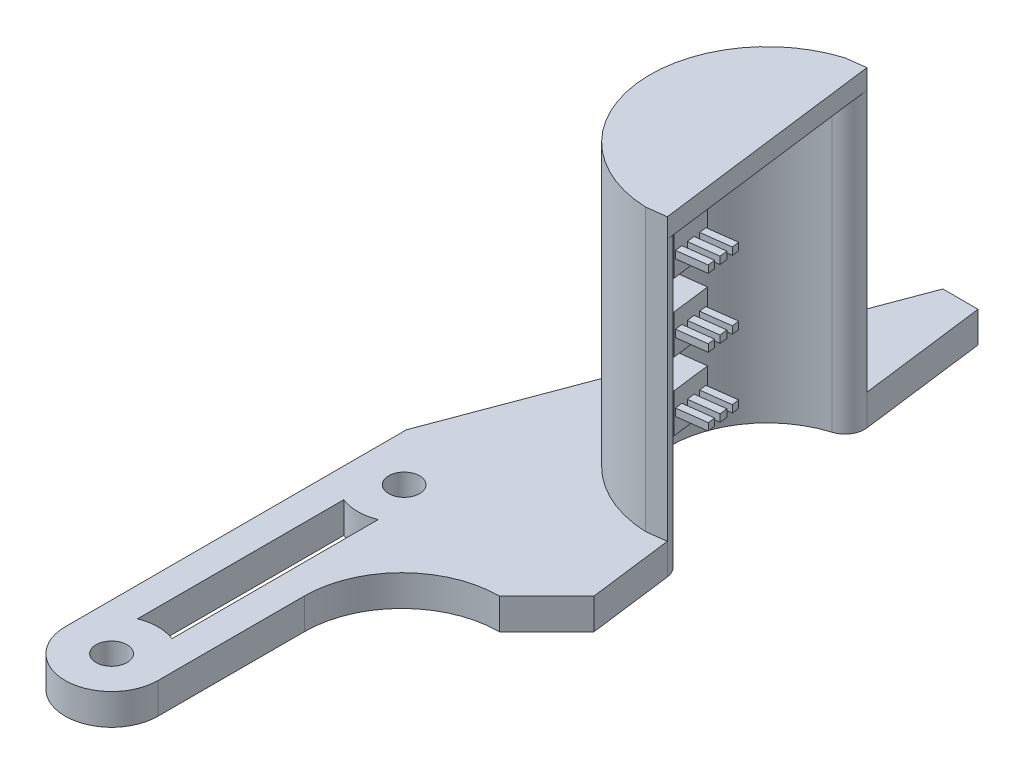
from build123d import *
from build123d.topology import SkipClean

# Parameters (mm, degrees)
CROQUIS1_R               = 1.5875
SALIENTE_EXTRUIR1_DEPTH  = 3.175
CORTAR_EXTRUIR1_DEPTH    = 3.175
CORTAR_EXTRUIR3_DEPTH    = 10
CROQUIS4_R               = 10
CORTAR_EXTRUIR4_DEPTH    = 10
REDONDEO1_R              = 2
BOSS_EXTRUDE1_DEPTH      = 26.82
BOSS_EXTRUDE2_DEPTH      = 2
BOSS_EXTRUDE5_REACH      = 56.057
BOSS_EXTRUDE5_END_RADIUS = 10
SKETCH6_W                = 4
SKETCH6_H                = 4
SKETCH7_W                = 0.75
SKETCH7_H                = 0.75
SKETCH7_W_2              = 0.804911675
BOSS_EXTRUDE6_DEPTH      = 3
LPATTERN1_COUNT          = 4
LPATTERN1_PITCH          = 7


with BuildPart() as part:
    # Croquis1 → Saliente-Extruir1 (new body)
    with BuildSketch(Plane(origin=(0, 0, 0), x_dir=(1, 0, 0), z_dir=(0, 1, 0))):
        with BuildLine():
            Line((-12.5, 0), (-12.5, -40))
            Line((-12.5, -40), (-2.975, -40))
            Line((-2.975, -40), (-2.975, -20))
            ThreePointArc((-2.975, -20), (-0.046067812, -12.928932188), (7.025, -10))
            Line((7.025, -10), (12.5, -10))
            Line((12.5, -10), (12.5, 40))
            Line((12.5, 40), (2.5, 40))
            Line((2.5, 40), (-12.5, 0))
        make_face()
        with Locations(Location((-7.7375, -5, 0), (0, 0, 270))):
            Circle(CROQUIS1_R, mode=Mode.SUBTRACT)
        with Locations(Location((-7.7375, -35, 0), (0, 0, 270))):
            Circle(CROQUIS1_R, mode=Mode.SUBTRACT)
    extrude(amount=SALIENTE_EXTRUIR1_DEPTH)

    # Croquis2 → Cortar-Extruir1 (cut)
    with BuildSketch(Plane(origin=(0, 3.175, 0), x_dir=(1, 0, 0), z_dir=(0, 1, 0))):
        Polygon((12.5, -10), (6.1, 40), (12.5, 40), align=None)
    extrude(amount=-CORTAR_EXTRUIR1_DEPTH, mode=Mode.SUBTRACT)

    # Croquis3 → Cortar-Extruir3 (cut)
    with BuildSketch(Plane(origin=(0, 3.175, 0), x_dir=(1, 0, 0), z_dir=(0, 1, 0))):
        with BuildLine():
            ThreePointArc((-5.975, -30.575635639), (-7.7375, -30.2375), (-9.5, -30.575635639))
            Line((-9.5, -30.575635639), (-9.5, -9.427055314))
            ThreePointArc((-9.5, -9.427055314), (-7.7375, -9.765), (-5.975, -9.427055314))
            Line((-5.975, -9.427055314), (-5.975, -14.803847577))
            Line((-5.975, -14.803847577), (-5.975, -30.575635639))
        make_face()
        with BuildLine():
            ThreePointArc((-12.5, -35), (-7.7375, -39.7625), (-2.975, -35))
            Line((-2.975, -35), (-2.975, -40))
            Line((-2.975, -40), (-12.5, -40))
            Line((-12.5, -40), (-12.5, -35))
        make_face()
    extrude(amount=-CORTAR_EXTRUIR3_DEPTH, mode=Mode.SUBTRACT)

    # Croquis4 → Cortar-Extruir4 (cut)
    with BuildSketch(Plane(origin=(0, 3.175, 0), x_dir=(1, 0, 0), z_dir=(0, 1, 0))):
        with Locations((9.274103387, 15.202317292)):
            Circle(CROQUIS4_R)
        Polygon((7.025, -10), (11.878723404, -5.146276596), (12.5, -10), align=None)
    extrude(amount=-CORTAR_EXTRUIR4_DEPTH, mode=Mode.SUBTRACT)

    # Redondeo1
    redondeo1_edges = [part.edges().sort_by_distance(p)[0] for p in [
        (8.004462032, 1.5875, -25.121390375),
        (10.543744741, 1.5875, -5.283244209),
    ]]
    fillet(redondeo1_edges, radius=REDONDEO1_R)

    # Sketch1 → Boss-Extrude1 (add)
    with SkipClean():  # the faces are left unmerged after this step: merging them gives an invalid solid
        with BuildSketch(Plane(origin=(0, 3.175, 0), x_dir=(1, 0, 0), z_dir=(0, 1, 0))):
            with BuildLine():
                Line((7.771843477, 26.938722839), (5.78802886, 26.684794568))
                ThreePointArc((5.78802886, 26.684794568), (-2.628784313, 13.678747666), (8.79254868, 3.211983474))
                Line((8.79254868, 3.211983474), (10.776363297, 3.465911745))
                ThreePointArc((10.776363297, 3.465911745), (10.143802127, 4.686471223), (8.872807798, 5.210372444))
                ThreePointArc((8.872807798, 5.210372444), (-0.644969697, 13.932675937), (6.369041281, 24.771048355))
                ThreePointArc((6.369041281, 24.771048355), (7.467102295, 25.59818866), (7.771843477, 26.938722839))
            make_face()
        extrude(amount=BOSS_EXTRUDE1_DEPTH)

    # Sketch2 → Boss-Extrude2 (add)
    with SkipClean():  # the faces are left unmerged after this step: merging them gives an invalid solid
        with BuildSketch(Plane(origin=(0, 29.995, 0), x_dir=(1, 0, 0), z_dir=(0, 1, 0))):
            with BuildLine():
                Line((10.776363297, 3.465911745), (7.771843477, 26.938722839))
                Line((7.771843477, 26.938722839), (5.78802886, 26.684794568))
                ThreePointArc((5.78802886, 26.684794568), (-2.628784313, 13.678747666), (8.79254868, 3.211983474))
                Line((8.79254868, 3.211983474), (10.776363297, 3.465911745))
            make_face()
        extrude(amount=BOSS_EXTRUDE2_DEPTH)

    # Boss-Extrude5: up to this cylinder (the profile starts inside it)
    with SkipClean():  # the faces are left unmerged after this step: merging them gives an invalid solid
        boss_extrude5_end = Plane(origin=(9.274103387, 26.995, -15.202317292), z_dir=(0, 1, 0)) * Cylinder(BOSS_EXTRUDE5_END_RADIUS, 133.114, mode=Mode.PRIVATE)
        # Sketch6 → Boss-Extrude5 (add, up to the surface)
        with BuildSketch(Plane(origin=(4.095783657, 0, -0.524260308), x_dir=(-0.12696413546540503, 0, -0.9919073083234755), z_dir=(0.9919073083234755, 0, -0.12696413546540503)), mode=Mode.PRIVATE) as boss_extrude5_sk1:
            with Locations((13.901811107, 26.995)):
                Rectangle(SKETCH6_W, SKETCH6_H)
        boss_extrude5_tool1 = extrude(boss_extrude5_sk1.sketch, amount=-BOSS_EXTRUDE5_REACH, mode=Mode.PRIVATE) & boss_extrude5_end
        boss_extrude5 = boss_extrude5_tool1.solids().sort_by_distance((2.330752, 26.995, -14.313568))[0]
        add(boss_extrude5)

    # Sketch7 → Boss-Extrude6 (add)
    with SkipClean():  # the faces are left unmerged after this step: merging them gives an invalid solid
        with BuildSketch(Plane(origin=(4.095783657, 0, -0.524260308), x_dir=(-0.12696413546540503, 0, -0.9919073083234755), z_dir=(0.9919073083234755, 0, -0.12696413546540503))):
            with Locations((15.329266944, 26.995)):
                Rectangle(SKETCH7_W, SKETCH7_H)
            with Locations((13.901811107, 26.995)):
                Rectangle(SKETCH7_W_2, SKETCH7_H)
            with Locations((12.474355269, 26.995)):
                Rectangle(SKETCH7_W, SKETCH7_H)
        boss_extrude6 = extrude(amount=BOSS_EXTRUDE6_DEPTH)

    # LPattern1: Boss-Extrude5, Boss-Extrude6 ×4
    with SkipClean():  # the faces are left unmerged after this step: merging them gives an invalid solid
        with Locations(*[(0, -i * LPATTERN1_PITCH, 0) for i in range(1, LPATTERN1_COUNT)]):
            add(boss_extrude5)
            add(boss_extrude6)


solid = part.part
